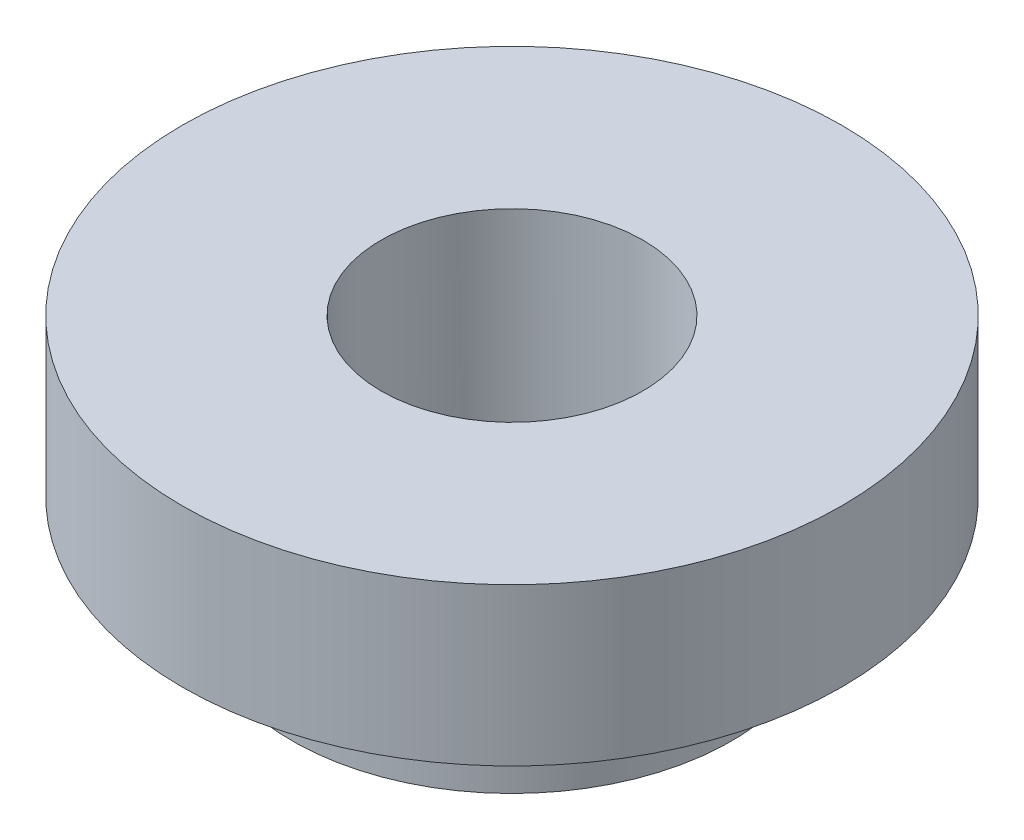
from build123d import *

# Parameters (mm, degrees)
TALADRO_ROSCADO_M31_D     = 2.5
TALADRO_ROSCADO_M31_DEPTH = 10
TALADRO_ROSCADO_M31_TIP   = 0.751075774


with BuildPart() as part:
    # Croquis1 → Revolución1 (revolve)
    with BuildSketch(Plane.XY):
        Polygon((0, 0), (3.15, 0), (3.15, -1.5), (2.1, -1.5), (2.1, -2.47), (0, -2.47), align=None)
    revolve(axis=Axis((0, 0, 0), (0, -1, 0)))

    # Taladro roscado M31
    with Locations(Plane(origin=(0, 0, 0), x_dir=(1, 0, 0), z_dir=(0, 1, 0))):
        with Locations((0, 0)):
            Hole(TALADRO_ROSCADO_M31_D / 2, depth=TALADRO_ROSCADO_M31_DEPTH)
            with Locations((0, 0, -(TALADRO_ROSCADO_M31_DEPTH + TALADRO_ROSCADO_M31_TIP / 2))):  # 118° drill point
                Cone(0, TALADRO_ROSCADO_M31_D / 2, TALADRO_ROSCADO_M31_TIP, mode=Mode.SUBTRACT)


solid = part.part
